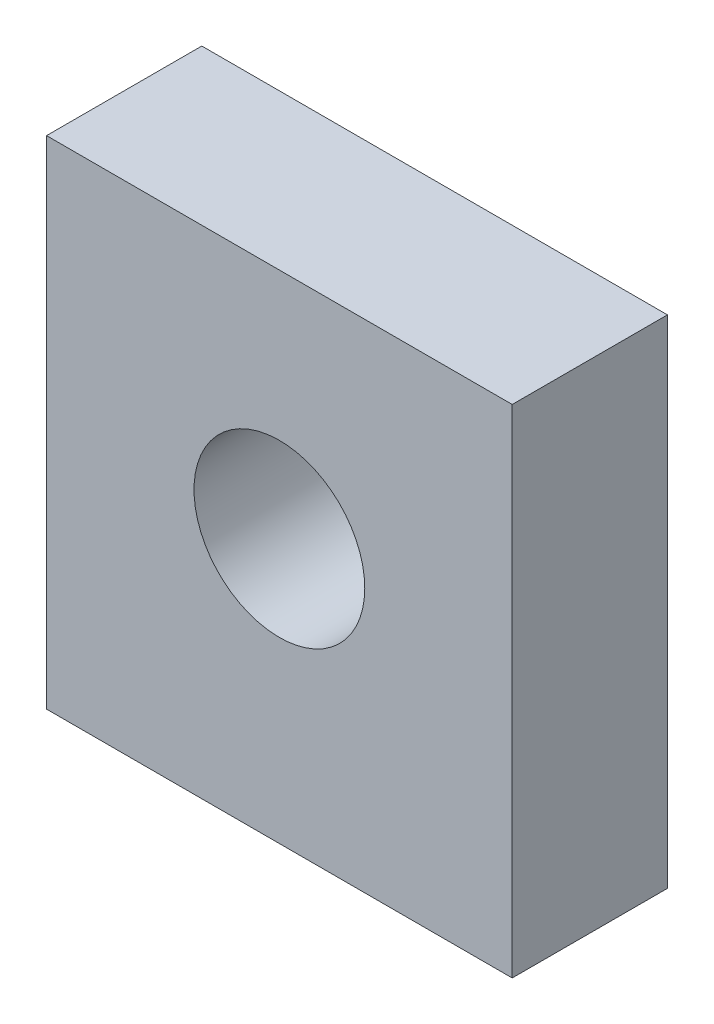
from build123d import *

# Parameters (mm, degrees)
SKETCH1_W             = 10
SKETCH1_H             = 32
BOSS_EXTRUDE1_DEPTH   = 30
M4_TAPPED_HOLE1_D     = 3.3
M4_TAPPED_HOLE1_DEPTH = 10.1
M4_TAPPED_HOLE1_TIP   = 0.991420021
SKETCH4_R             = 5.5
CUT_EXTRUDE2_DEPTH    = 10


with BuildPart() as part:
    # Sketch1 → Boss-Extrude1 (new body)
    with BuildSketch(Plane(origin=(0, 0, 0), x_dir=(0, 0, -1), z_dir=(1, 0, 0))):
        with Locations((5, 16)):
            Rectangle(SKETCH1_W, SKETCH1_H)
    extrude(amount=BOSS_EXTRUDE1_DEPTH)

    # M4 Tapped Hole1
    with Locations(Plane(origin=(0, 0, 0), x_dir=(-1, 0, 0), z_dir=(0, -1, 0))):
        with Locations((-5, 5), (-25, 5)):
            Hole(M4_TAPPED_HOLE1_D / 2, depth=M4_TAPPED_HOLE1_DEPTH)
            with Locations((0, 0, -(M4_TAPPED_HOLE1_DEPTH + M4_TAPPED_HOLE1_TIP / 2))):  # 118° drill point
                Cone(0, M4_TAPPED_HOLE1_D / 2, M4_TAPPED_HOLE1_TIP, mode=Mode.SUBTRACT)

    # Sketch4 → Cut-Extrude2 (cut)
    with BuildSketch(Plane.XY):
        with Locations((15, 17)):
            Circle(SKETCH4_R)
    extrude(amount=-CUT_EXTRUDE2_DEPTH, mode=Mode.SUBTRACT)


solid = part.part
